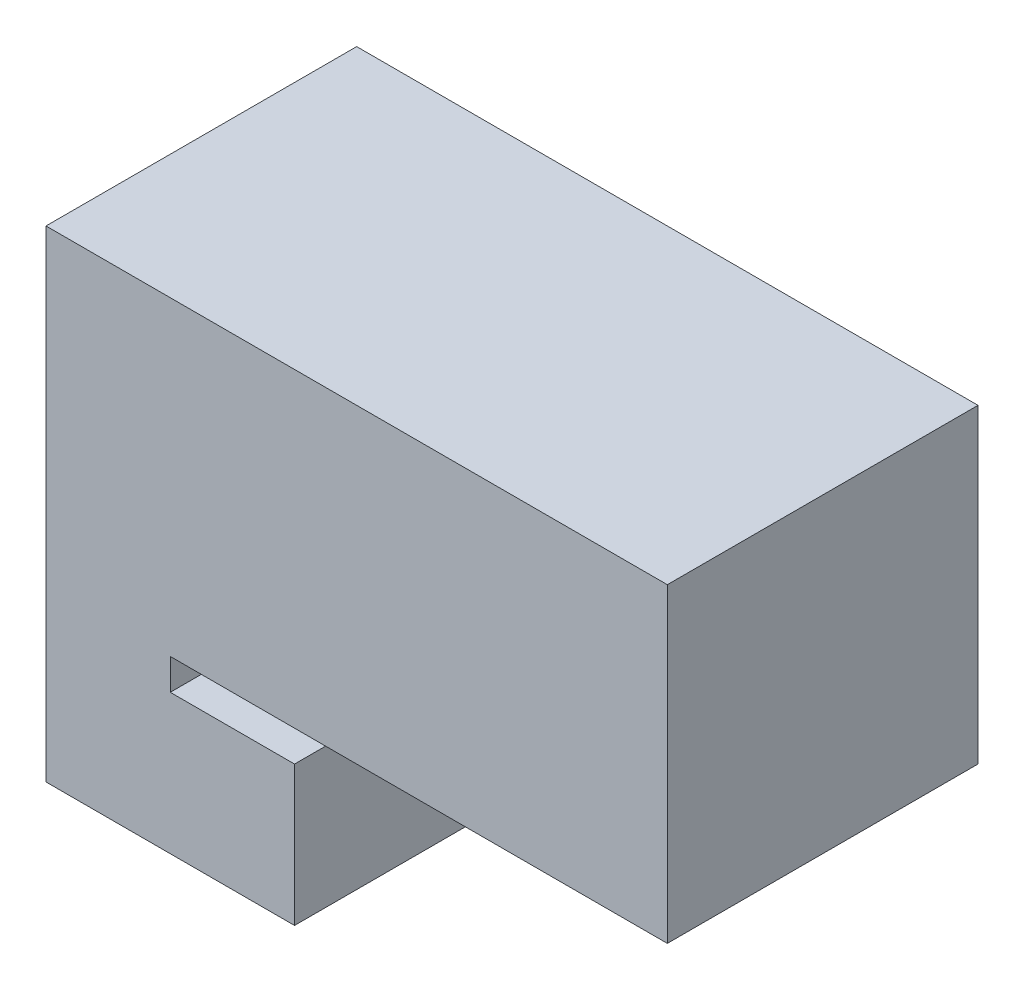
from build123d import *

# Parameters (mm, degrees)
BOSS_EXTRUDE1_DEPTH = 63.5
SKETCH2_W           = 63.5
SKETCH2_H           = 63.5
BOSS_EXTRUDE2_DEPTH = 101.6


with BuildPart() as part:
    # Sketch1 → Boss-Extrude1 (new body)
    with BuildSketch(Plane.XY):
        Polygon((0, 0), (0, 28.575), (-25.4, 28.575), (-25.4, 98.425), (-50.8, 98.425), (-50.8, 0), align=None)
    extrude(amount=BOSS_EXTRUDE1_DEPTH)

    # Sketch2 → Boss-Extrude2 (add)
    with BuildSketch(Plane(origin=(-25.4, 0, 0), x_dir=(0, 0, -1), z_dir=(1, 0, 0))):
        with Locations((-31.75, 66.675)):
            Rectangle(SKETCH2_W, SKETCH2_H)
    extrude(amount=BOSS_EXTRUDE2_DEPTH)


solid = part.part
